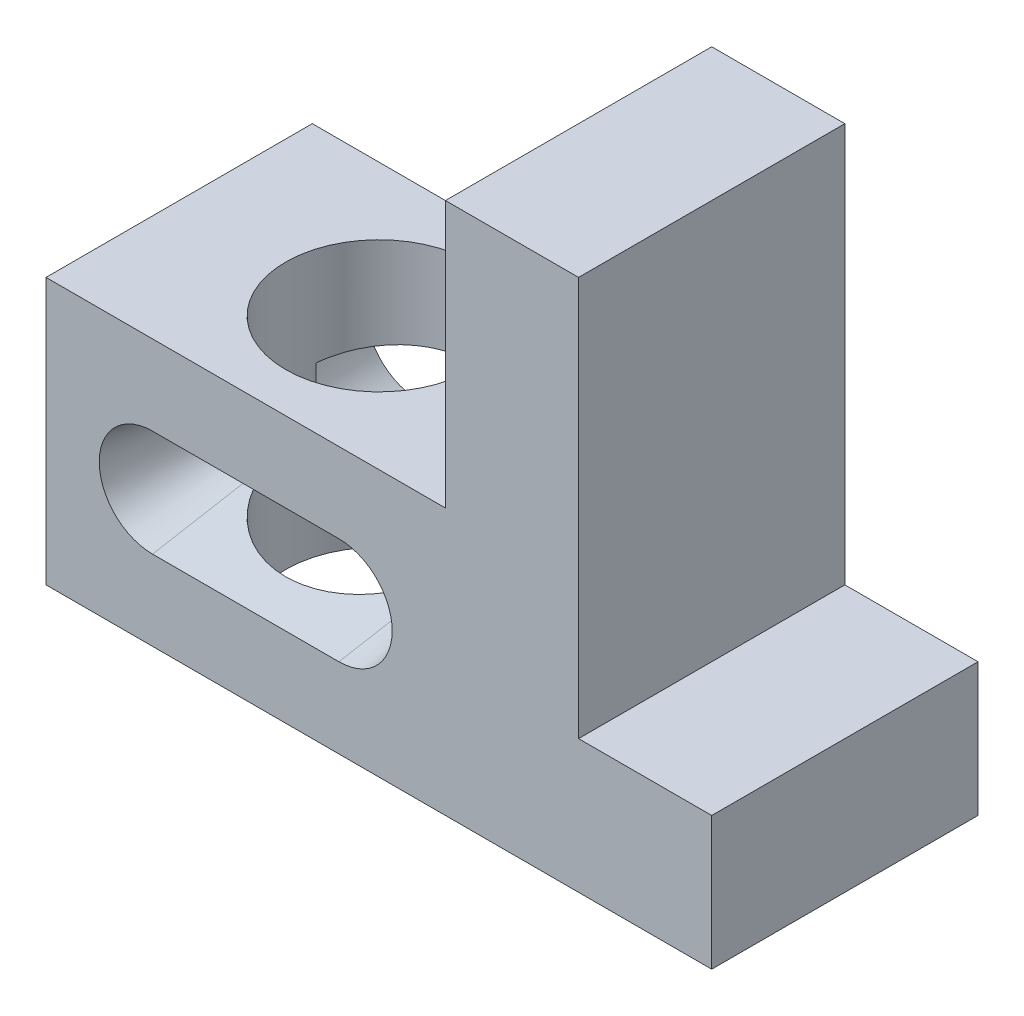
from build123d import *

# Parameters (mm, degrees)
BASE_EXTRUSION_DEPTH = 50
FRONT_CUT_DEPTH      = 20
FRONT_CUT_TAPER      = 10
BACK_CUT_DEPTH       = 20
BACK_CUT_TAPER       = 10
TOP_CUT_SKETCH_R     = 17.5
TOP_CUT_DEPTH        = 50


with BuildPart() as part:
    # Base Sketch → Base Extrusion (new body)
    with BuildSketch(Plane.XY):
        Polygon((0, 0), (0, 50), (75, 50), (75, 100), (100, 100), (100, 25), (125, 25), (125, 0), align=None)
    extrude(amount=BASE_EXTRUSION_DEPTH)

    # Front Cut Sketch → Front Cut (cut)
    with BuildSketch(Plane.XY.offset(50)):
        with BuildLine():
            ThreePointArc((20, 35), (10, 25), (20, 15))
            Line((20, 15), (55, 15))
            ThreePointArc((55, 15), (65, 25), (55, 35))
            Line((55, 35), (20, 35))
        make_face()
    extrude(amount=-FRONT_CUT_DEPTH, taper=FRONT_CUT_TAPER, mode=Mode.SUBTRACT)

    # Back Cut Sketch → Back Cut (cut)
    with BuildSketch(Plane(origin=(0, 0, 0), x_dir=(-1, 0, 0), z_dir=(0, 0, -1))):
        with BuildLine():
            ThreePointArc((-20, 15), (-10, 25), (-20, 35))
            Line((-20, 35), (-55, 35))
            ThreePointArc((-55, 35), (-65, 25), (-55, 15))
            Line((-55, 15), (-20, 15))
        make_face()
    extrude(amount=-BACK_CUT_DEPTH, taper=BACK_CUT_TAPER, mode=Mode.SUBTRACT)

    # Top Cut Sketch → Top Cut (cut)
    with BuildSketch(Plane(origin=(0, 50, 0), x_dir=(1, 0, 0), z_dir=(0, 1, 0))):
        with Locations((37.5, -25)):
            Circle(TOP_CUT_SKETCH_R)
    extrude(amount=-TOP_CUT_DEPTH, mode=Mode.SUBTRACT)


solid = part.part
